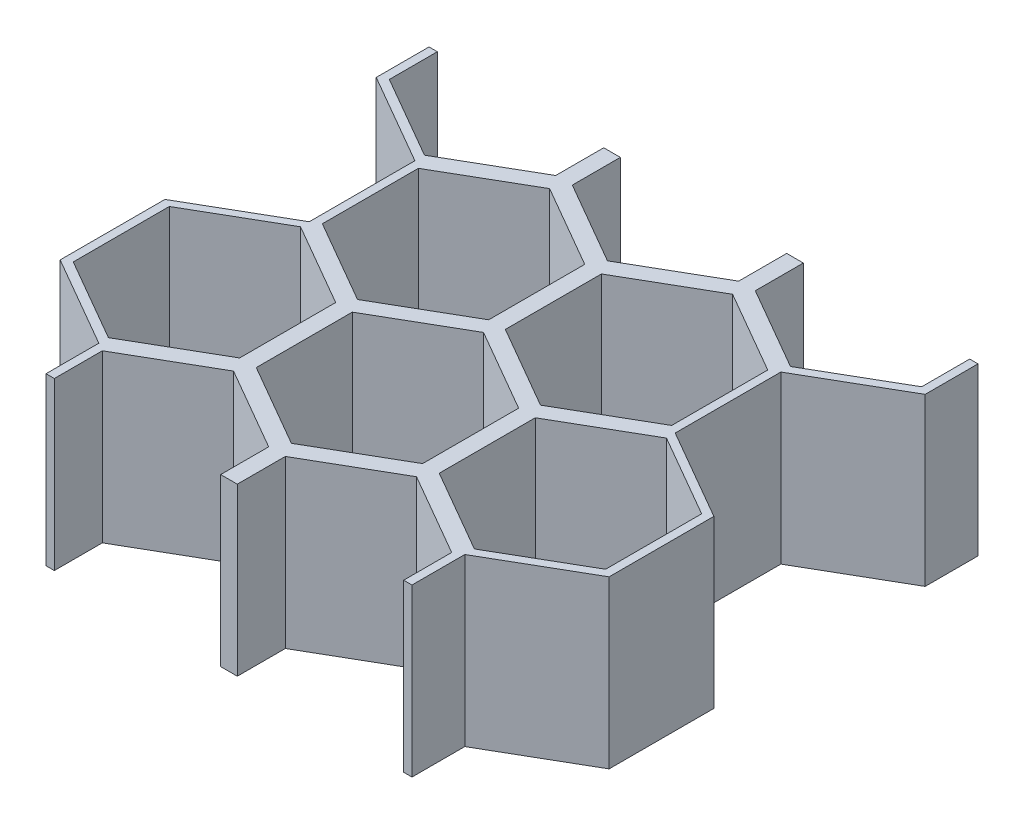
from build123d import *

# Parameters (mm, degrees)
BOSS_EXTRUDE2_DEPTH = 20
CUT_EXTRUDE1_DEPTH  = 21


with BuildPart() as part:
    # Sketch1 → Boss-Extrude2 (new body)
    with BuildSketch(Plane(origin=(0, 0, 0), x_dir=(1, 0, 0), z_dir=(0, 1, 0))):
        Polygon((21, -13.279056191), (21, -19.052558883), (23, -19.052558883), (23, -13.279056191), (33, -7.505553499), (43, -13.279056191), (43, -19.052558883), (45, -19.052558883), (45, -13.279056191), (55, -7.505553499), (65, -13.279056191), (65, -19.052558883), (67, -19.052558883), (67, -13.279056191), (77, -7.505553499), (77, 7.400435733), (67, 13.173938425), (67, 24.720943809), (77, 30.494446501), (77, 38), (76, 38), (76, 32.226497308), (66, 26.452994616), (56, 32.226497308), (56, 38), (54, 38), (54, 32.226497308), (44, 26.452994616), (34, 32.226497308), (34, 38), (32, 38), (32, 32.226497308), (22, 26.452994616), (12, 32.226497308), (12, 38), (11, 38), (11, 30.494446501), (21, 24.720943809), (21, 13.173938425), (11, 7.400435733), (11, -7.505553499), align=None)
        Polygon((12, 5.773502692), (22, 11.547005384), (32, 5.773502692), (32, -5.773502692), (22, -11.547005384), (12, -5.773502692), align=None, mode=Mode.SUBTRACT)
        Polygon((34, 5.773502692), (44, 11.547005384), (54, 5.773502692), (54, -5.773502692), (44, -11.547005384), (34, -5.773502692), align=None, mode=Mode.SUBTRACT)
        Polygon((56, 5.773502692), (66, 11.547005384), (76, 5.773502692), (76, -5.773502692), (66, -11.547005384), (56, -5.773502692), align=None, mode=Mode.SUBTRACT)
        Polygon((43, 13.173938425), (33, 7.400435733), (23, 13.173938425), (23, 24.720943809), (33, 30.494446501), (43, 24.720943809), align=None, mode=Mode.SUBTRACT)
        Polygon((65, 13.173938425), (55, 7.400435733), (45, 13.173938425), (45, 24.720943809), (55, 30.494446501), (65, 24.720943809), align=None, mode=Mode.SUBTRACT)
    extrude(amount=BOSS_EXTRUDE2_DEPTH)

    # Sketch2 → Cut-Extrude1 (cut, through all)
    with BuildSketch(Plane(origin=(0, 20, 0), x_dir=(1, 0, 0), z_dir=(0, 1, 0))):
        Polygon((11, 6.245735195), (22, 12.596588156), (22, 25.298294078), (11, 31.649147039), (2.295872016, -19.052558883), (22, -19.052558883), (22, -12.701705922), (11, -6.350852961), align=None)
        Polygon((77, 31.649147039), (85.704127984, -19.052558883), (66, -19.052558883), (66, -12.701705922), (77, -6.350852961), (77, 6.245735195), (66, 12.596588156), (66, 25.298294078), align=None)
    extrude(amount=-CUT_EXTRUDE1_DEPTH, mode=Mode.SUBTRACT)


solid = part.part
